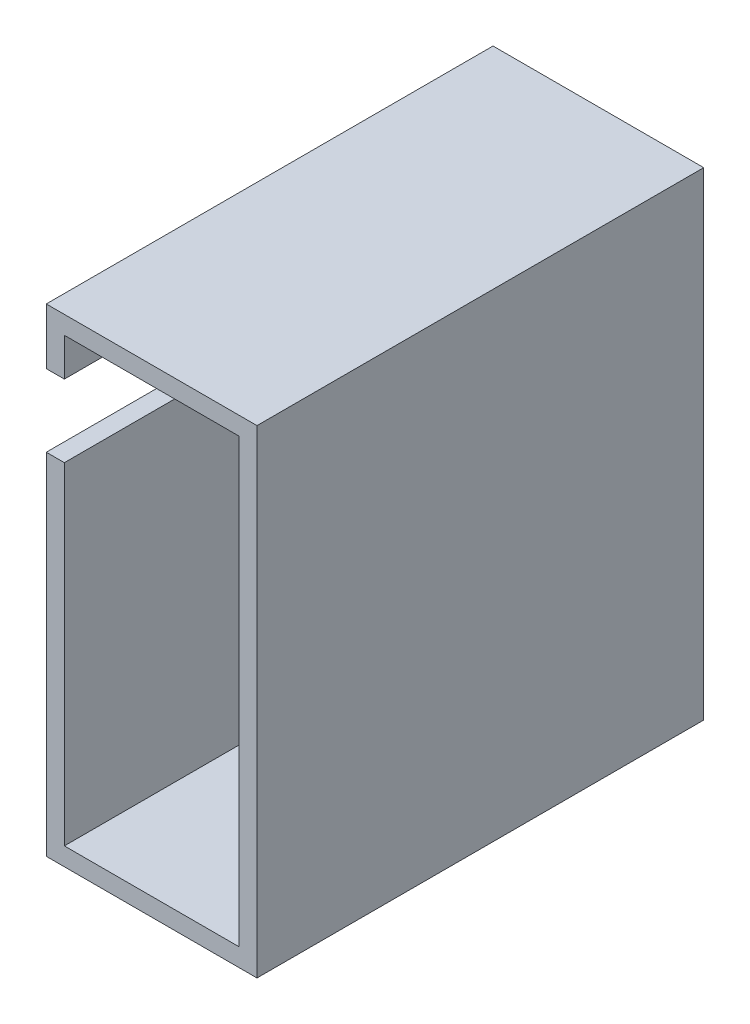
from build123d import *

# Parameters (mm, degrees)
SKETCH1_W           = 23.3
SKETCH1_H           = 52.9
SKETCH1_W_2         = 19.3
SKETCH1_H_2         = 48.9
BOSS_EXTRUDE1_DEPTH = 47.4
SKETCH2_W           = 23.3
SKETCH2_H           = 52.9
BOSS_EXTRUDE2_DEPTH = 2
CUT_EXTRUDE1_DEPTH  = 2


with BuildPart() as part:
    # Sketch1 → Boss-Extrude1 (new body)
    with BuildSketch(Plane.XY):
        with Locations((9.65, 24.45)):
            Rectangle(SKETCH1_W, SKETCH1_H)
        with Locations((9.65, 24.45)):
            Rectangle(SKETCH1_W_2, SKETCH1_H_2, mode=Mode.SUBTRACT)
    extrude(amount=BOSS_EXTRUDE1_DEPTH)

    # Sketch2 → Boss-Extrude2 (add)
    with BuildSketch(Plane(origin=(0, 0, 0), x_dir=(-1, 0, 0), z_dir=(0, 0, -1))):
        with Locations((-9.65, 24.45)):
            Rectangle(SKETCH2_W, SKETCH2_H)
    extrude(amount=BOSS_EXTRUDE2_DEPTH)

    # Sketch3 → Cut-Extrude1 (cut)
    with BuildSketch(Plane.ZY.offset(2)):
        with BuildLine():
            Line((3, 44.7), (47.4, 44.7))
            ThreePointArc((47.4, 44.7), (51.4, 40.7), (47.4, 36.7))
            Line((47.4, 36.7), (3, 36.7))
            ThreePointArc((3, 36.7), (-1, 40.7), (3, 44.7))
        make_face()
    extrude(amount=-CUT_EXTRUDE1_DEPTH, mode=Mode.SUBTRACT)


solid = part.part
